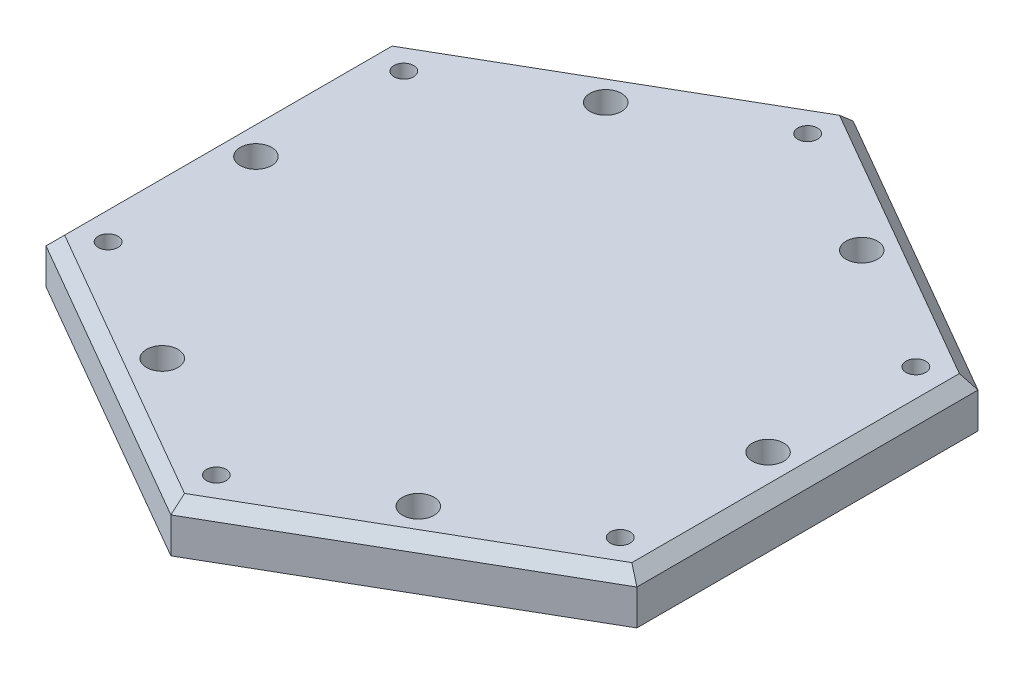
from build123d import *

# Parameters (mm, degrees)
EXTRUDE_1_DEPTH     = 12
CHAMFER_1_SIZE      = 3
SKETCH_2_R          = 4
CUT_EXTRUDE_1_DEPTH = 13
M6X1_0_1_D          = 5


with BuildPart() as part:
    # 草圖1 → 填料-伸長1 (new body)
    with BuildSketch(Plane(origin=(0, 0, 0), x_dir=(1, 0, 0), z_dir=(0, 1, 0))):
        Polygon((0, 86.602540378), (-75, 43.301270189), (-75, -43.301270189), (0, -86.602540378), (75, -43.301270189), (75, 43.301270189), align=None)
    extrude(amount=EXTRUDE_1_DEPTH)

    # 導角1
    chamfer_1_edges = [part.edges().sort_by_distance(p)[0] for p in [
        (-75, 12, 0),
        (-37.5, 12, 64.951905284),
        (37.5, 12, 64.951905284),
        (75, 12, 0),
        (37.5, 12, -64.951905284),
        (-37.5, 12, -64.951905284),
    ]]
    chamfer(chamfer_1_edges, length=CHAMFER_1_SIZE)

    # 草圖2 → 除料-伸長1 (cut, through all)
    with BuildSketch(Plane(origin=(0, 12, 0), x_dir=(1, 0, 0), z_dir=(0, 1, 0))):
        with Locations((32.5, 56.291651246)):
            Circle(SKETCH_2_R)
        with Locations((32.5, -56.291651246)):
            Circle(SKETCH_2_R)
        with Locations((65, 0)):
            Circle(SKETCH_2_R)
        with Locations((-65, 0)):
            Circle(SKETCH_2_R)
        with Locations((-32.5, 56.291651246)):
            Circle(SKETCH_2_R)
        with Locations((-32.5, -56.291651246)):
            Circle(SKETCH_2_R)
    extrude(amount=-CUT_EXTRUDE_1_DEPTH, mode=Mode.SUBTRACT)

    # M6x1.0 螺紋孔1 (through all)
    with Locations(Plane(origin=(-65, 12, -37.527767497), x_dir=(0, 0, 1), z_dir=(0, 1, 0))):
        with Locations((0, 0), (-37.527767498, 65), (0, 130), (75.055534994, 130), (112.583302492, 65), (75.055534994, 0)):
            Hole(M6X1_0_1_D / 2)


solid = part.part
